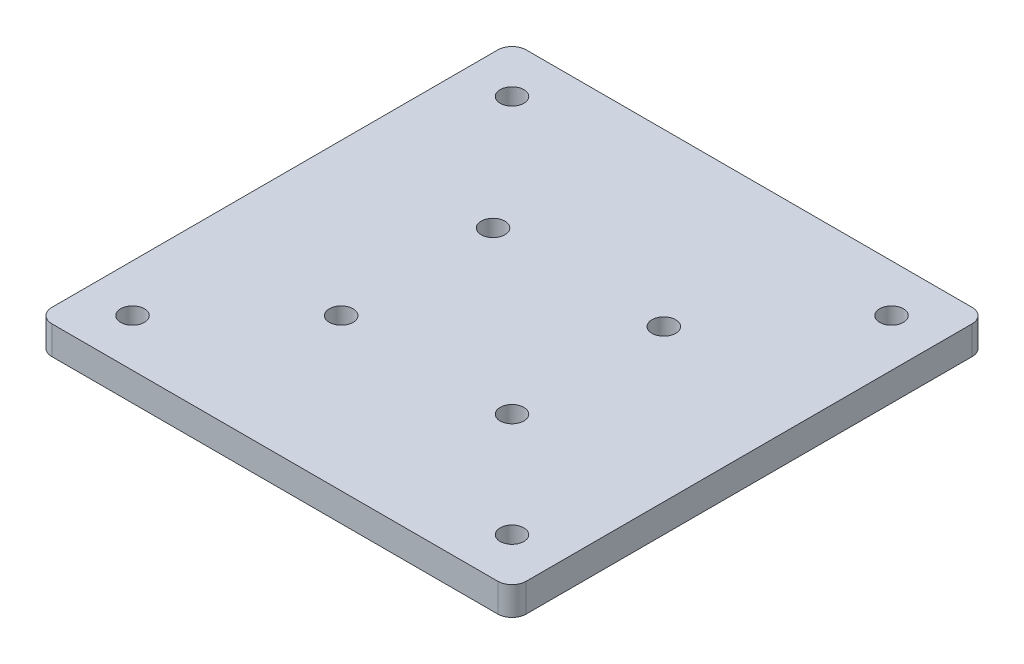
from build123d import *

# Parameters (mm, degrees)
SKETCH1_W           = 100
SKETCH1_H           = 100
SKETCH1_R           = 2.5
BOSS_EXTRUDE1_DEPTH = 6
FILLET1_R           = 3
FILLET2_R           = 3


with BuildPart() as part:
    # Sketch1 → Boss-Extrude1 (new body)
    with BuildSketch(Plane(origin=(0, 0, 0), x_dir=(1, 0, 0), z_dir=(0, 1, 0))):
        with Locations((40, 40)):
            Rectangle(SKETCH1_W, SKETCH1_H)
        Circle(SKETCH1_R, mode=Mode.SUBTRACT)
        with Locations((80, 0)):
            Circle(SKETCH1_R, mode=Mode.SUBTRACT)
        with Locations((0, 80)):
            Circle(SKETCH1_R, mode=Mode.SUBTRACT)
        with Locations((80, 80)):
            Circle(SKETCH1_R, mode=Mode.SUBTRACT)
        with Locations((22, 22)):
            Circle(SKETCH1_R, mode=Mode.SUBTRACT)
        with Locations((58, 22)):
            Circle(SKETCH1_R, mode=Mode.SUBTRACT)
        with Locations((22, 54)):
            Circle(SKETCH1_R, mode=Mode.SUBTRACT)
        with Locations((58, 54)):
            Circle(SKETCH1_R, mode=Mode.SUBTRACT)
    extrude(amount=BOSS_EXTRUDE1_DEPTH)

    # Fillet1
    fillet1_edges = [part.edges().sort_by_distance(p)[0] for p in [
        (90, 3, 10),
        (-10, 3, 10),
    ]]
    fillet(fillet1_edges, radius=FILLET1_R)

    # Fillet2
    fillet2_edges = [part.edges().sort_by_distance(p)[0] for p in [
        (-10, 3, -90),
        (90, 3, -90),
    ]]
    fillet(fillet2_edges, radius=FILLET2_R)


solid = part.part
